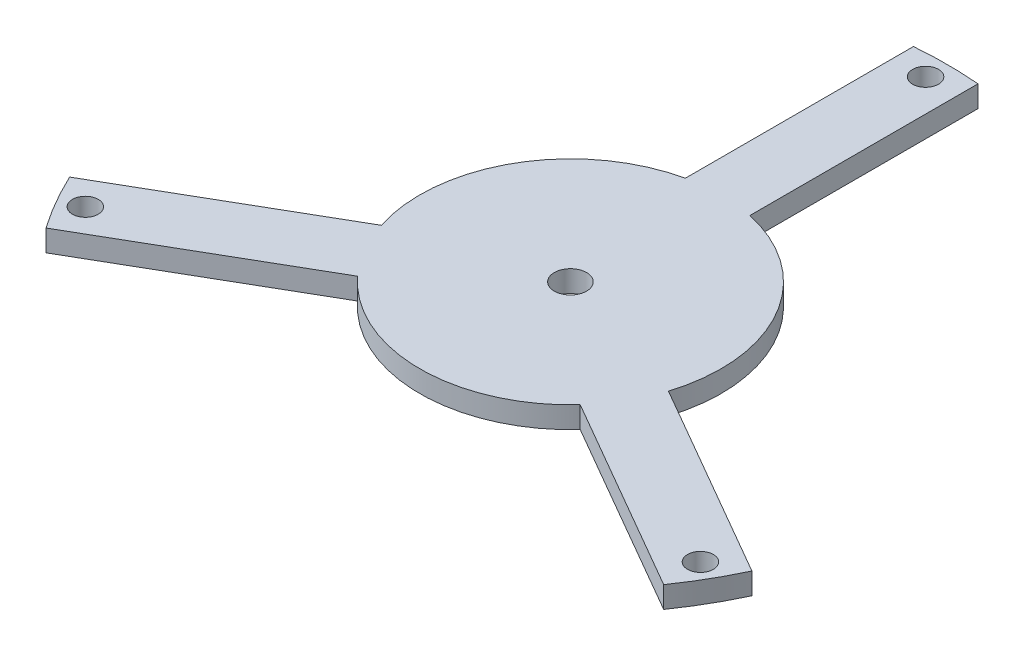
from build123d import *

# Parameters (mm, degrees)
SKETCH_1_R          = 6
EXTRUDE_1_DEPTH     = 10
SKETCH_2_R          = 7.5
CUT_EXTRUDE_1_DEPTH = 11


with BuildPart() as part:
    # 草图1 → 凸台-拉伸1 (new body)
    with BuildSketch(Plane(origin=(0, 0, 0), x_dir=(1, 0, 0), z_dir=(0, 1, 0))):
        with BuildLine():
            Line((-15, 174.355957742), (-15, 68.373971656))
            ThreePointArc((-15, 68.373971656), (-60.621778265, 35), (-66.713596412, -21.196604771))
            Line((-66.713596412, -21.196604771), (-158.496688705, -74.187597814))
            ThreePointArc((-158.496688705, -74.187597814), (-151.554445662, -87.5), (-143.496688705, -100.168359928))
            Line((-143.496688705, -100.168359928), (-51.713596412, -47.177366885))
            ThreePointArc((-51.713596412, -47.177366885), (0, -70), (51.713596412, -47.177366885))
            Line((51.713596412, -47.177366885), (143.496688705, -100.168359928))
            ThreePointArc((143.496688705, -100.168359928), (151.554445662, -87.5), (158.496688705, -74.187597814))
            Line((158.496688705, -74.187597814), (66.713596412, -21.196604771))
            ThreePointArc((66.713596412, -21.196604771), (60.621778265, 35), (15, 68.373971656))
            Line((15, 68.373971656), (15, 174.355957742))
            ThreePointArc((15, 174.355957742), (0, 175), (-15, 174.355957742))
        make_face()
        with Locations((0, 165)):
            Circle(SKETCH_1_R, mode=Mode.SUBTRACT)
        with Locations((142.894191624, -82.5)):
            Circle(SKETCH_1_R, mode=Mode.SUBTRACT)
        with Locations((-142.894191624, -82.5)):
            Circle(SKETCH_1_R, mode=Mode.SUBTRACT)
    extrude(amount=EXTRUDE_1_DEPTH)

    # 草图2 → 切除-拉伸1 (cut, through all)
    with BuildSketch(Plane(origin=(0, 10, 0), x_dir=(1, 0, 0), z_dir=(0, 1, 0))):
        Circle(SKETCH_2_R)
    extrude(amount=-CUT_EXTRUDE_1_DEPTH, mode=Mode.SUBTRACT)


solid = part.part
